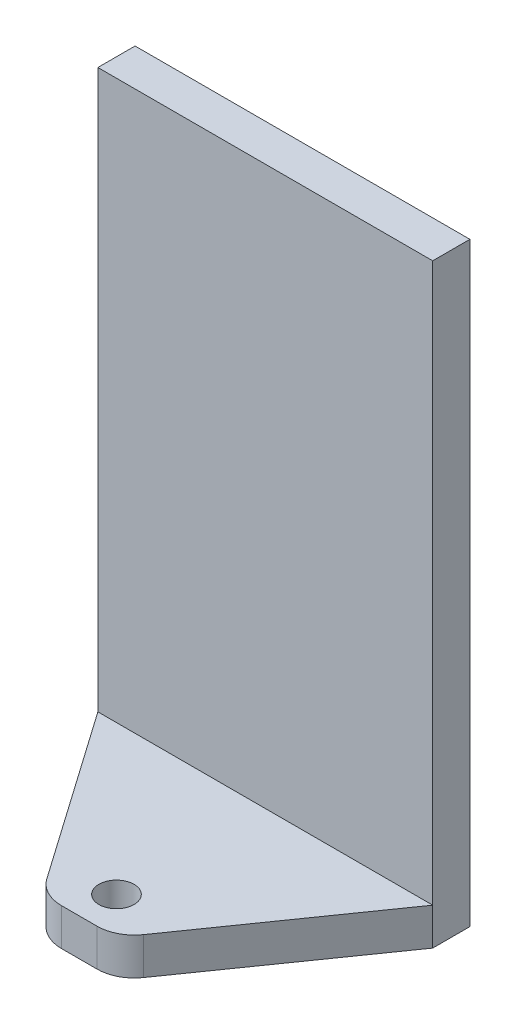
from build123d import *

# Parameters (mm, degrees)
SKETCH1_W           = 57.15
SKETCH1_H           = 101.6
BOSS_EXTRUDE1_DEPTH = 3.175
SKETCH2_W           = 57.15
SKETCH2_H           = 57.15
BOSS_EXTRUDE2_DEPTH = 6.35
SKETCH4_R           = 3
CUT_EXTRUDE2_DEPTH  = 7.35
CUT_EXTRUDE3_DEPTH  = 7.35
FILLET1_R           = 6.35


with BuildPart() as part:
    # Sketch1 → Boss-Extrude1 (new body, symmetric)
    with BuildSketch(Plane.XY):
        Rectangle(SKETCH1_W, SKETCH1_H)
    extrude(amount=BOSS_EXTRUDE1_DEPTH, both=True)

    # Sketch2 → Boss-Extrude2 (add)
    with BuildSketch(Plane.XZ.offset(50.8)):
        with Locations((0, 25.4)):
            Rectangle(SKETCH2_W, SKETCH2_H)
    extrude(amount=-BOSS_EXTRUDE2_DEPTH)

    # Sketch4 → Cut-Extrude2 (cut, through all)
    with BuildSketch(Plane(origin=(0, -44.45, 0), x_dir=(1, 0, 0), z_dir=(0, 1, 0))):
        with Locations((0, -28.575)):
            Circle(SKETCH4_R)
    extrude(amount=-CUT_EXTRUDE2_DEPTH, mode=Mode.SUBTRACT)

    # Sketch5 → Cut-Extrude3 (cut, through all)
    with BuildSketch(Plane(origin=(0, -44.45, 0), x_dir=(1, 0, 0), z_dir=(0, 1, 0))):
        Polygon((-28.575, -3.175), (-6.35, -34.925), (6.35, -34.925), (28.575, -3.175), (28.575, -53.975), (-28.575, -53.975), align=None)
    extrude(amount=-CUT_EXTRUDE3_DEPTH, mode=Mode.SUBTRACT)

    # Fillet1
    fillet1_edges = [part.edges().sort_by_distance(p)[0] for p in [
        (-6.35, -47.625, 34.925),
        (6.35, -47.625, 34.925),
    ]]
    fillet(fillet1_edges, radius=FILLET1_R)


solid = part.part
